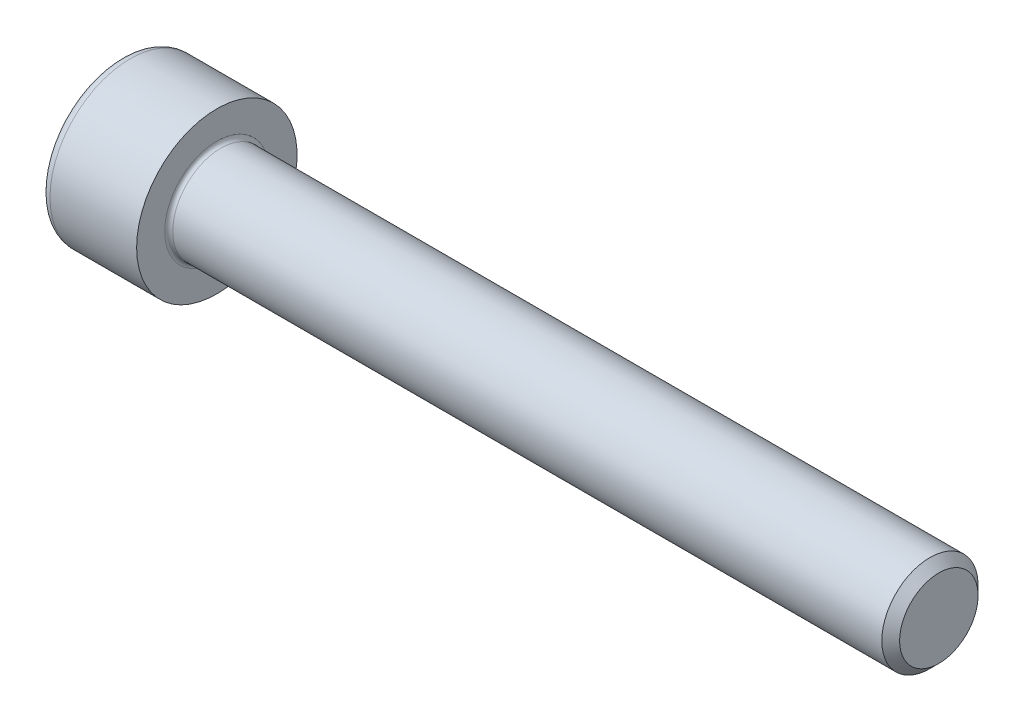
from build123d import *

# Parameters (mm, degrees)
FILLET1_R   = 0.25
FILLET2_R   = 0.6
HEX_2_DEPTH = 3


with BuildPart() as part:
    # BodySke → Base-Revolve (revolve)
    with BuildSketch(Plane.XY):
        Polygon((0, 0), (0, 5), (6, 5), (6, 3), (50.4455, 3), (51, 2.4455), (51, 0), align=None)
    revolve(axis=Axis((-31.75, 0, 0), (1, 0, 0)))

    # Fillet1
    fillet1_edges = [part.edges().sort_by_distance(p)[0] for p in [
        (6, -3, 0),
    ]]
    fillet(fillet1_edges, radius=FILLET1_R)

    # Fillet2
    fillet2_edges = [part.edges().sort_by_distance(p)[0] for p in [
        (0, -5, 0),
    ]]
    fillet(fillet2_edges, radius=FILLET2_R)

    # Sketch2 → Hex-PreBroach (revolve, cut)
    with BuildSketch(Plane.XY):
        Polygon((0, 2.51), (3, 2.51), (4.449149176, 0), (0, 0), align=None)
    revolve(axis=Axis((0, 0, 0), (1, 0, 0)), mode=Mode.SUBTRACT)

    # Sketch3 → Hex 2 (cut)
    with BuildSketch(Plane(origin=(0, 0, 0), x_dir=(0, 0.5, 0.866025404), z_dir=(-1, 0, 0))):
        Polygon((1.449149176, 2.51), (-1.449149176, 2.51), (-2.898298351, 0), (-1.449149176, -2.51), (1.449149176, -2.51), (2.898298351, 0), align=None)
    extrude(amount=-HEX_2_DEPTH, mode=Mode.SUBTRACT)


solid = part.part
